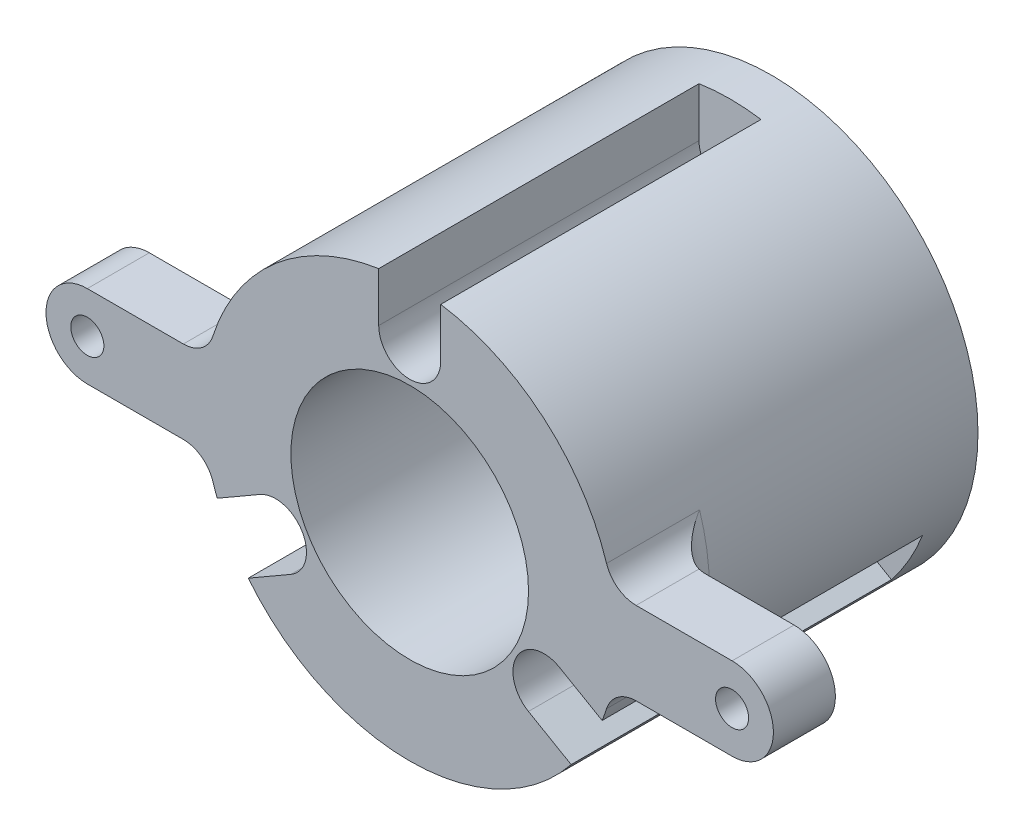
from build123d import *

# Parameters (mm, degrees)
SKETCH1_R           = 10.5
BOSS_EXTRUDE1_DEPTH = 35
SKETCH1_3_R         = 1.0999999999987757
SKETCH1_3_R_2       = 1.0999999999999885
SKETCH1_3_R_3       = 1.0999999999996088
BOSS_EXTRUDE2_DEPTH = 4
CUT_EXTRUDE1_START  = -30
SKETCH2_R           = 11.5
SKETCH2_R_2         = 10.5
CUT_EXTRUDE1_DEPTH  = 30
BOSS_EXTRUDE3_START = -6
SKETCH2_3_R         = 1.599999999999998
SKETCH2_3_R_2       = 1.599999999999995
BOSS_EXTRUDE3_DEPTH = 6
FILLET1_R           = 3
SKETCH3_R           = 3.0000000000000004
CUT_EXTRUDE2_DEPTH  = 54.516726422680286


with BuildPart() as part:
    # Sketch1 → Boss-Extrude1 (new body)
    with BuildSketch(Plane.XY):
        with BuildLine():
            ThreePointArc((2.9999999999998876, 15.000000000000563), (1.0993e-12, 12.000000000001776), (-2.9999999999976876, 15.000000000000563))
            Line((-2.9999999999988978, 15.000000000000593), (-2.9999999999988947, 19.77371993328577))
            ThreePointArc((-2.999999999998834, 19.773719933285363), (-17.320508075688434, 10.00000000000059), (-18.62454378954378, -7.288783755289101))
            Line((-18.624543789543775, -7.288783755289104), (-14.490381056766635, -4.901923788646557))
            ThreePointArc((-14.490381056766635, -4.901923788646555), (-11.490381056766648, -4.9019237886465765), (-9.990381056766658, -7.499999999999886))
            ThreePointArc((-9.990381056766658, -7.499999999999887), (-10.39230484541335, -8.9999999999999), (-11.490381056766685, -10.098076211353218))
            Line((-11.490381056766685, -10.098076211353215), (-15.624543789543822, -12.484936177995765))
            ThreePointArc((-15.624543789543823, -12.484936177995765), (-7.473e-14, -20), (15.624543789543718, -12.484936177995895))
            Line((15.624543789544566, -12.484936177996572), (11.490381056767449, -10.098076211353982))
            ThreePointArc((11.490381056767642, -10.098076211353645), (10.392304845414507, -6.000000000000834), (14.490381056767315, -4.9019237886476965))
            Line((14.490381056767498, -4.901923788647381), (18.624543789544614, -7.28878375528997))
            ThreePointArc((18.62454378954359, -7.28878375528958), (19.653127941766318, -3.7087143465848165), (20, -4.9e-15))
            ThreePointArc((20, 0), (15.165750888103432, 13.038404810404913), (3.000000000001001, 19.773719933285037))
            Line((3.000000000001103, 19.773719933285708), (3.0000000000011, 15.000000000000533))
        make_face()
        Circle(SKETCH1_R, mode=Mode.SUBTRACT)
    extrude(amount=BOSS_EXTRUDE1_DEPTH)

    # Sketch1_3 → Boss-Extrude2 (add)
    # profile 1 of 3: a face of its own
    with BuildSketch(Plane.XY):
        with BuildLine():
            Line((-2.9999999999988947, 19.77371993328577), (-2.9999999999988978, 15.000000000000593))
            ThreePointArc((-2.9999999999976876, 15.000000000000563), (1.0993e-12, 12.000000000001776), (2.9999999999998876, 15.000000000000563))
            Line((3.0000000000011, 15.000000000000533), (3.000000000001103, 19.773719933285708))
            ThreePointArc((3.000000000001001, 19.773719933285037), (1.09368e-12, 20), (-2.999999999998834, 19.773719933285363))
        make_face()
        with Locations((1.09985e-12, 15.000000000000563)):
            Circle(SKETCH1_3_R, mode=Mode.SUBTRACT)
    # profile 2 of 3: a face of its own
    with BuildSketch(Plane.XY):
        with BuildLine():
            Line((-14.490381056766635, -4.901923788646557), (-18.624543789543775, -7.288783755289104))
            ThreePointArc((-18.62454378954378, -7.288783755289101), (-17.32050807568887, -9.999999999999833), (-15.624543789543823, -12.484936177995765))
            Line((-15.624543789543822, -12.484936177995765), (-11.490381056766685, -10.098076211353215))
            ThreePointArc((-11.490381056766683, -10.098076211353217), (-10.392304845413328, -5.999999999999909), (-14.490381056766637, -4.901923788646555))
        make_face()
        with Locations((-12.99038105676666, -7.499999999999886)):
            Circle(SKETCH1_3_R_2, mode=Mode.SUBTRACT)
    # profile 3 of 3: a face of its own
    with BuildSketch(Plane.XY):
        with BuildLine():
            ThreePointArc((15.624543789543718, -12.484936177995895), (17.320508075688696, -10.000000000000131), (18.62454378954359, -7.28878375528958))
            Line((18.624543789544614, -7.28878375528997), (14.490381056767498, -4.901923788647381))
            ThreePointArc((14.490381056767315, -4.9019237886476965), (10.392304845414507, -6.000000000000834), (11.490381056767642, -10.098076211353645))
            Line((11.490381056767449, -10.098076211353982), (15.624543789544566, -12.484936177996572))
        make_face()
        with Locations((12.99038105676748, -7.5000000000006715)):
            Circle(SKETCH1_3_R_3, mode=Mode.SUBTRACT)
    extrude(amount=BOSS_EXTRUDE2_DEPTH)

    # Sketch2 → Cut-Extrude1 (cut)
    with BuildSketch(Plane.XY.offset(35).offset(CUT_EXTRUDE1_START)):
        Circle(SKETCH2_R)
        Circle(SKETCH2_R_2, mode=Mode.SUBTRACT)
    extrude(amount=CUT_EXTRUDE1_DEPTH, mode=Mode.SUBTRACT)

    # Sketch2_3 → Boss-Extrude3 (add)
    # profile 1 of 2: a face of its own
    with BuildSketch(Plane.XY.offset(35).offset(BOSS_EXTRUDE3_START)):
        with BuildLine():
            Line((19.59591794226542, -3.9999999999999982), (31.2, -3.9999999999999982))
            ThreePointArc((31.2, -3.999999999999999), (35.199999999999996, -2.4e-16), (31.2, 3.999999999999999))
            Line((31.2, 3.9999999999999982), (19.59591794226542, 3.9999999999999982))
            ThreePointArc((19.595917942265423, 3.999999999999999), (19.999999999999996, -8.9e-16), (19.595917942265427, -3.9999999999999996))
        make_face()
        with Locations((31.2, 0)):
            Circle(SKETCH2_3_R, mode=Mode.SUBTRACT)
    # profile 2 of 2: a face of its own
    with BuildSketch(Plane.XY.offset(35).offset(BOSS_EXTRUDE3_START)):
        with BuildLine():
            ThreePointArc((-19.595917942265448, -3.9999999999998597), (-19.999999999999996, 1.4456e-13), (-19.595917942265395, 4.000000000000134))
            Line((-19.59591794226539, 4.000000000000135), (-31.19999999999997, 4.000000000000216))
            ThreePointArc((-31.19999999999997, 4.000000000000215), (-35.199999999999996, 2.4678e-13), (-31.200000000000028, -3.9999999999997793))
            Line((-31.200000000000028, -3.9999999999997806), (-19.595917942265448, -3.9999999999998614))
        make_face()
        with Locations((-31.2, 2.1787e-13)):
            Circle(SKETCH2_3_R_2, mode=Mode.SUBTRACT)
    extrude(amount=BOSS_EXTRUDE3_DEPTH)

    # Fillet1
    fillet1_edges = [part.edges().sort_by_distance(p)[0] for p in [
        (19.595917942265423, -3.999999999999999, 32),
        (20, 2.2e-16, 29),
        (19.595917942265423, 3.9999999999999987, 32),
        (-19.595917942265395, 4.000000000000135, 32),
        (-19.999999999999996, 1.4011e-13, 29),
        (-19.595917942265448, -3.999999999999861, 32),
    ]]
    fillet(fillet1_edges, radius=FILLET1_R)

    # Sketch3 → Cut-Extrude2 (cut, through all)
    with BuildSketch(Plane(origin=(0, 0, 0), x_dir=(1, 0, 0), z_dir=(0, 1, 0))):
        with Locations((0, -13.499999999999998)):
            Circle(SKETCH3_R)
    extrude(amount=-CUT_EXTRUDE2_DEPTH, mode=Mode.SUBTRACT)


solid = part.part
